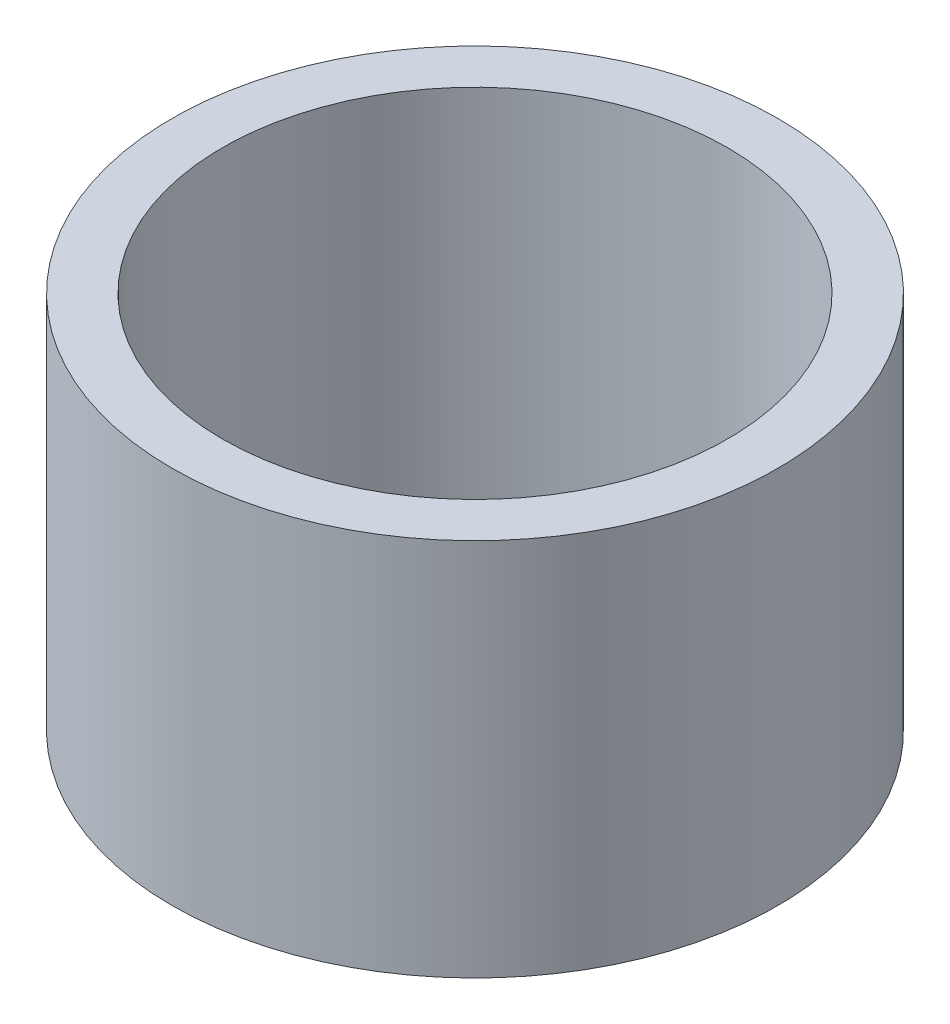
from build123d import *

# Parameters (mm, degrees)
SKETCH1_R           = 480
SKETCH1_R_2         = 400
BOSS_EXTRUDE1_DEPTH = 600


with BuildPart() as part:
    # Sketch1 → Boss-Extrude1 (new body)
    with BuildSketch(Plane(origin=(0, 0, 0), x_dir=(1, 0, 0), z_dir=(0, 1, 0))):
        Circle(SKETCH1_R)
        Circle(SKETCH1_R_2, mode=Mode.SUBTRACT)
    extrude(amount=BOSS_EXTRUDE1_DEPTH)


solid = part.part
